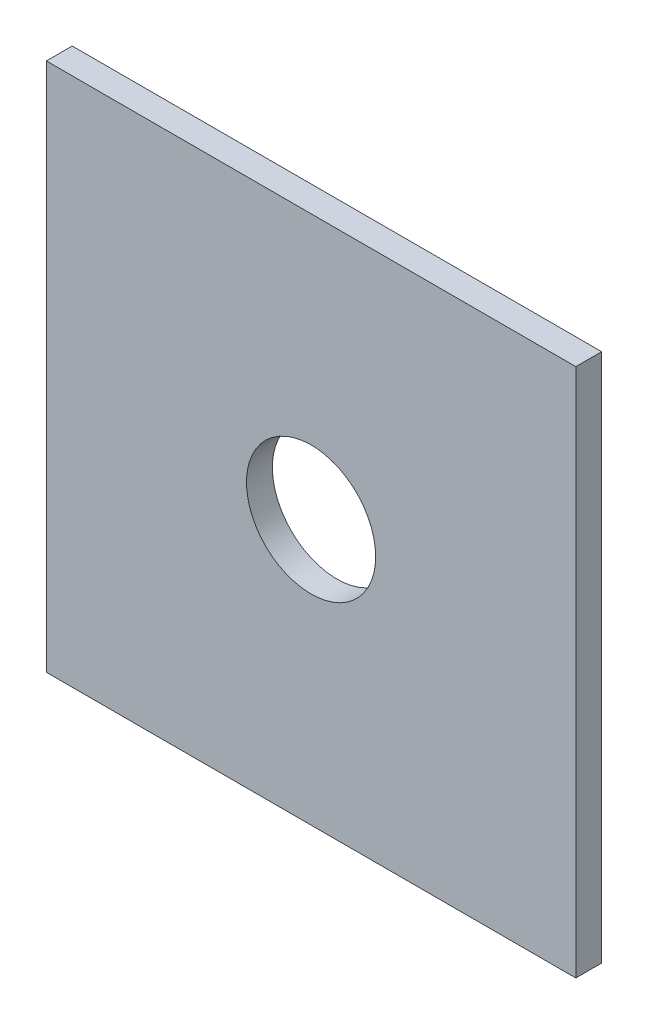
from build123d import *

# Parameters (mm, degrees)
SKETCH1_W           = 41
SKETCH1_H           = 41
BOSS_EXTRUDE1_DEPTH = 2
SKETCH2_R           = 5
CUT_EXTRUDE2_DEPTH  = 3


with BuildPart() as part:
    # Sketch1 → Boss-Extrude1 (new body)
    with BuildSketch(Plane.XY):
        with Locations((54.5, -202.5)):
            Rectangle(SKETCH1_W, SKETCH1_H)
    extrude(amount=BOSS_EXTRUDE1_DEPTH)

    # Sketch2 → Cut-Extrude2 (cut, through all)
    with BuildSketch(Plane.XY):
        with Locations((54.5, -202.5)):
            Circle(SKETCH2_R)
    extrude(amount=CUT_EXTRUDE2_DEPTH, mode=Mode.SUBTRACT)


solid = part.part
